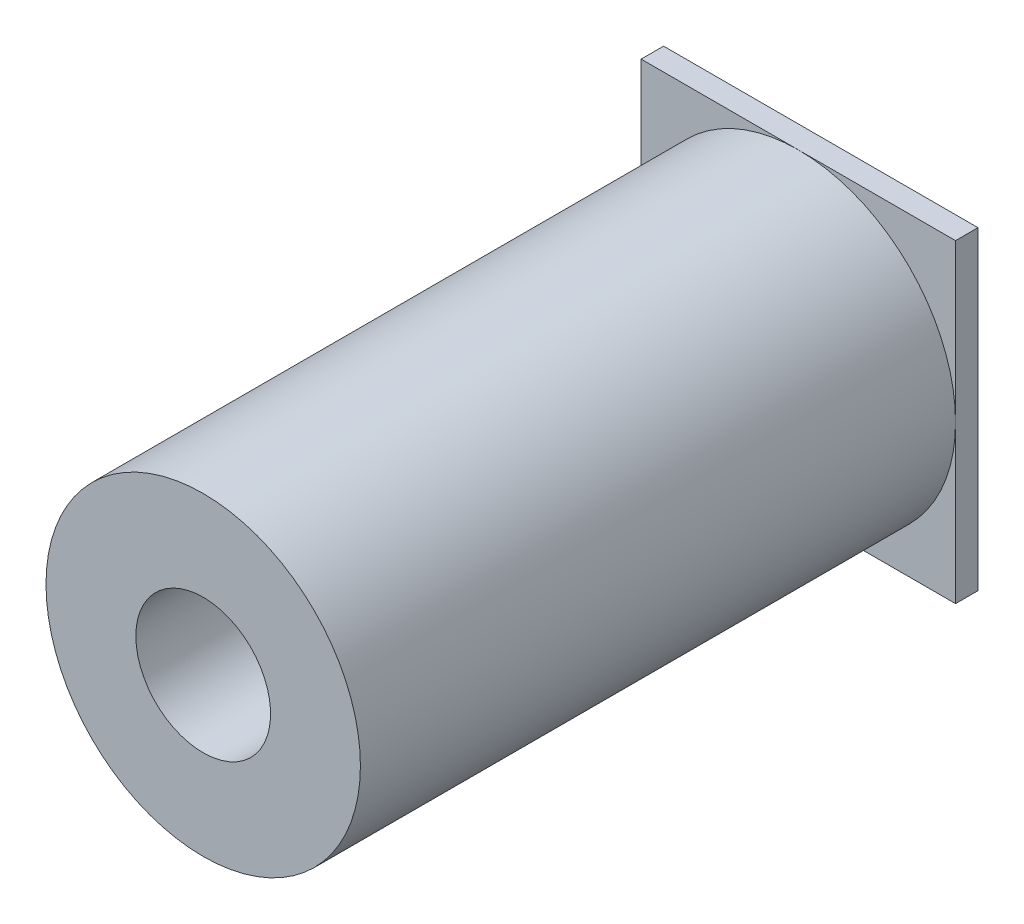
from build123d import *

# Parameters (mm, degrees)
SKETCH1_W           = 28
SKETCH1_H           = 28
BOSS_EXTRUDE1_DEPTH = 2
SKETCH2_R           = 14
BOSS_EXTRUDE2_DEPTH = 53
SKETCH3_R           = 6
CUT_EXTRUDE1_DEPTH  = 56


with BuildPart() as part:
    # Sketch1 → Boss-Extrude1 (new body)
    with BuildSketch(Plane.XY):
        Rectangle(SKETCH1_W, SKETCH1_H)
    extrude(amount=BOSS_EXTRUDE1_DEPTH)

    # Sketch2 → Boss-Extrude2 (add)
    with BuildSketch(Plane.XY.offset(2)):
        Circle(SKETCH2_R)
    extrude(amount=BOSS_EXTRUDE2_DEPTH)

    # Sketch3 → Cut-Extrude1 (cut, through all)
    with BuildSketch(Plane(origin=(0, 0, 0), x_dir=(-1, 0, 0), z_dir=(0, 0, -1))):
        Circle(SKETCH3_R)
    extrude(amount=-CUT_EXTRUDE1_DEPTH, mode=Mode.SUBTRACT)


solid = part.part
